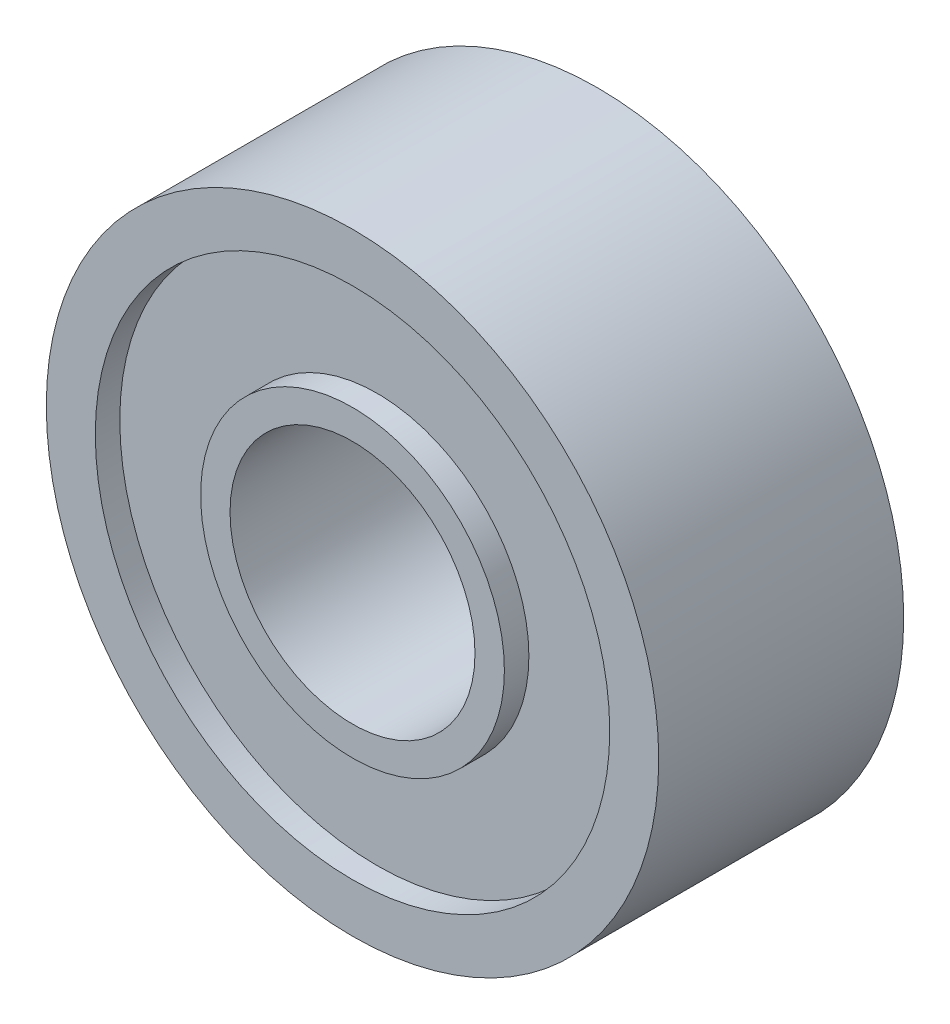
from build123d import *

# Parameters (mm, degrees)
SKETCH1_R           = 12.5
SKETCH1_R_2         = 5
BOSS_EXTRUDE1_DEPTH = 5
SKETCH2_R           = 10.5
SKETCH2_R_2         = 6.2
CUT_EXTRUDE1_DEPTH  = 1


with BuildPart() as part:
    # Sketch1 → Boss-Extrude1 (new body, symmetric)
    with BuildSketch(Plane.XY):
        Circle(SKETCH1_R)
        Circle(SKETCH1_R_2, mode=Mode.SUBTRACT)
    extrude(amount=BOSS_EXTRUDE1_DEPTH, both=True)

    # Sketch2 → Cut-Extrude1 (cut)
    with BuildSketch(Plane.XY.offset(5)):
        Circle(SKETCH2_R)
        Circle(SKETCH2_R_2, mode=Mode.SUBTRACT)
    cut_extrude1 = extrude(amount=-CUT_EXTRUDE1_DEPTH, mode=Mode.SUBTRACT)

    # Mirror1: Cut-Extrude1 across plane
    add(cut_extrude1.mirror(Plane.XY), mode=Mode.SUBTRACT)


solid = part.part
